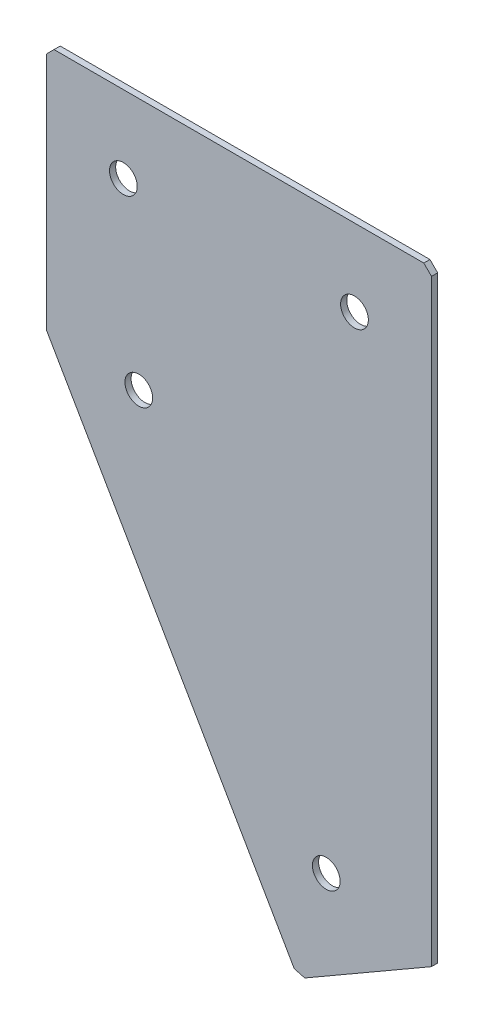
from build123d import *

# Parameters (mm, degrees)
EXTRUDE_1_DEPTH   = 2
HOLE_WIZARD_M81_D = 9
CHAMFER_1_SIZE    = 2.5


with BuildPart() as part:
    # Эскиз3 → Бобышка-Вытянуть1 (new body)
    with BuildSketch(Plane(origin=(0, 0, 0), x_dir=(1, 0, 0), z_dir=(0, 0, -1))):
        Polygon((0, 0), (125, 0), (125, 196.506350946), (81.698729811, 221.506350946), (0, 80), align=None)
    extrude(amount=EXTRUDE_1_DEPTH)

    # Отверстие с зазором M81 (through all)
    with Locations(Plane(origin=(0, 0, -2), x_dir=(1, 0, 0), z_dir=(0, 0, -1))):
        with Locations((25, 25), (100, 25), (30, 81.961524227), (90.849364905, 187.355715851)):
            Hole(HOLE_WIZARD_M81_D / 2)

    # Фаска1
    chamfer_1_edges = [part.edges().sort_by_distance(p)[0] for p in [
        (81.698729811, -221.506350946, -1),
        (125, 0, -1),
        (0, 0, -1),
    ]]
    chamfer(chamfer_1_edges, length=CHAMFER_1_SIZE)


solid = part.part
